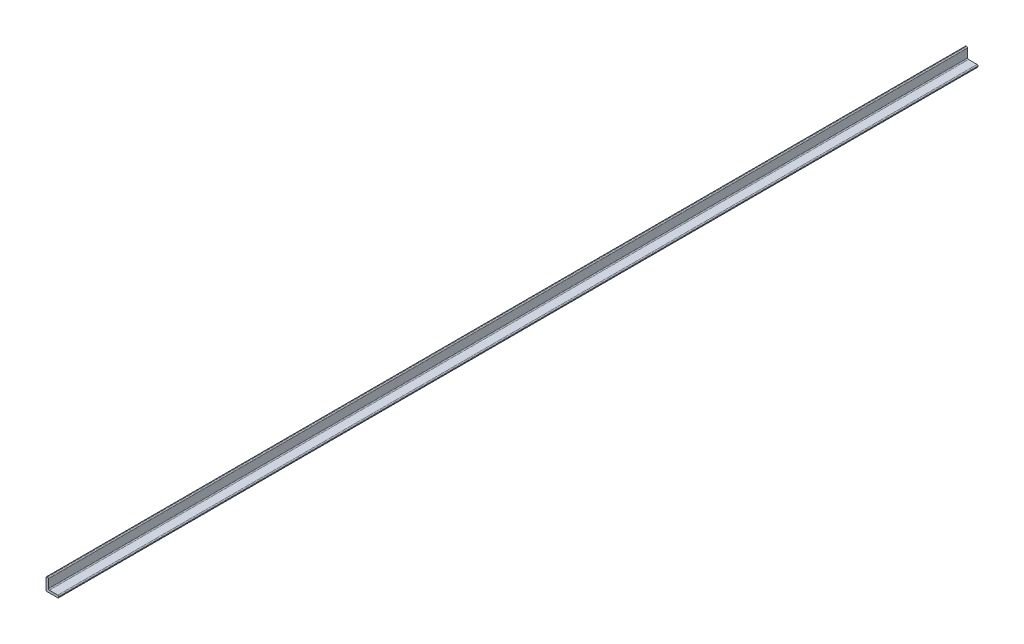
from build123d import *

# Parameters (mm, degrees)
BOSS_EXTRUDE1_DEPTH      = 914.4
BOSS_EXTRUDE1_DEPTH_BACK = 914.4
FILLET1_R                = 1.905


with BuildPart() as part:
    # Sketch4 → Boss-Extrude1 (new body, two sides)
    with BuildSketch(Plane.XY) as boss_extrude1_sk:
        with BuildLine():
            Line((-7.9375, -6.0325), (-7.9375, 12.7))
            Line((-7.9375, 12.7), (-12.7, 12.7))
            Line((-12.7, 12.7), (-12.7, -12.7))
            Line((-12.7, -12.7), (12.7, -12.7))
            Line((12.7, -12.7), (12.7, -7.9375))
            Line((12.7, -7.9375), (-6.0325, -7.9375))
            ThreePointArc((-6.0325, -7.9375), (-7.379538418, -7.379538418), (-7.9375, -6.0325))
        make_face()
    extrude(amount=BOSS_EXTRUDE1_DEPTH)
    extrude(boss_extrude1_sk.sketch, amount=-BOSS_EXTRUDE1_DEPTH_BACK)

    # Fillet1
    fillet1_edges = [part.edges().sort_by_distance(p)[0] for p in [
        (-7.9375, 12.7, 0),
        (12.7, -7.9375, 0),
        (12.7, -12.7, 0),
        (-12.7, -12.7, 0),
        (-12.7, 12.7, 0),
    ]]
    fillet(fillet1_edges, radius=FILLET1_R)


solid = part.part
